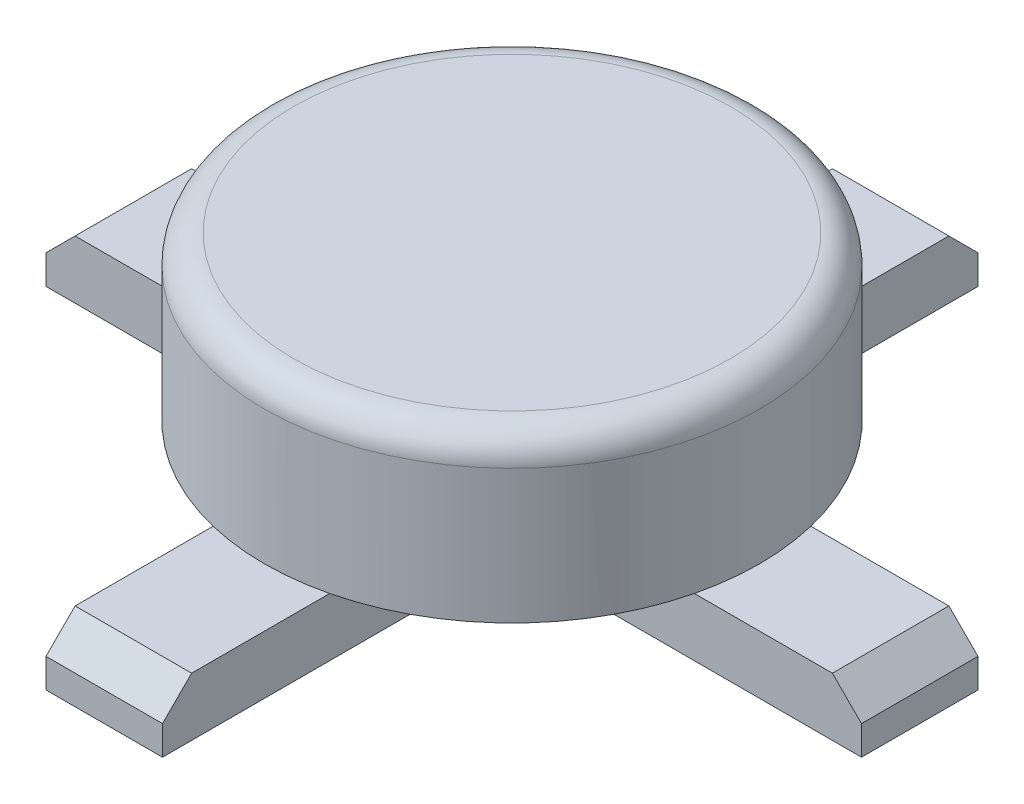
from build123d import *

# Parameters (mm, degrees)
SKETCH_1_R      = 4.25
EXTRUDE_1_DEPTH = 2.8
FILLET_1_R      = 0.5
SKETCH_2_W      = 14
SKETCH_2_H      = 2
EXTRUDE_2_DEPTH = 1
SKETCH_3_W      = 2
SKETCH_3_H      = 14
EXTRUDE_3_DEPTH = 1
CHAMFER_1_SIZE  = 0.5
CHAMFER_2_SIZE  = 0.5
CHAMFER_3_SIZE  = 0.5


with BuildPart() as part:
    # 草图1 → 凸台-拉伸1 (new body)
    with BuildSketch(Plane(origin=(0, 0, 0), x_dir=(1, 0, 0), z_dir=(0, 1, 0))):
        with Locations(Location((0, 0, 0), (0, 0, 270))):  # turned: the seam where the file's is
            Circle(SKETCH_1_R)
    extrude(amount=EXTRUDE_1_DEPTH)

    # 圆角1
    fillet_1_edges = [part.edges().sort_by_distance(p)[0] for p in [
        (0, 2.8, -4.25),
    ]]
    fillet(fillet_1_edges, radius=FILLET_1_R)

    # 草图2 → 凸台-拉伸2 (add)
    with BuildSketch(Plane.XZ):
        Rectangle(SKETCH_2_W, SKETCH_2_H)
    extrude(amount=EXTRUDE_2_DEPTH)

    # 草图3 → 凸台-拉伸3 (add)
    with BuildSketch(Plane.XZ):
        Rectangle(SKETCH_3_W, SKETCH_3_H)
    extrude(amount=EXTRUDE_3_DEPTH)

    # 倒角1
    chamfer_1_edges = [part.edges().sort_by_distance(p)[0] for p in [
        (0, 0, 7),
    ]]
    chamfer(chamfer_1_edges, length=CHAMFER_1_SIZE)

    # 倒角2
    chamfer_2_edges = [part.edges().sort_by_distance(p)[0] for p in [
        (7, 0, 0),
    ]]
    chamfer(chamfer_2_edges, length=CHAMFER_2_SIZE)

    # 倒角3
    chamfer_3_edges = [part.edges().sort_by_distance(p)[0] for p in [
        (-7, 0, 0),
        (0, 0, -7),
    ]]
    chamfer(chamfer_3_edges, length=CHAMFER_3_SIZE)


solid = part.part
